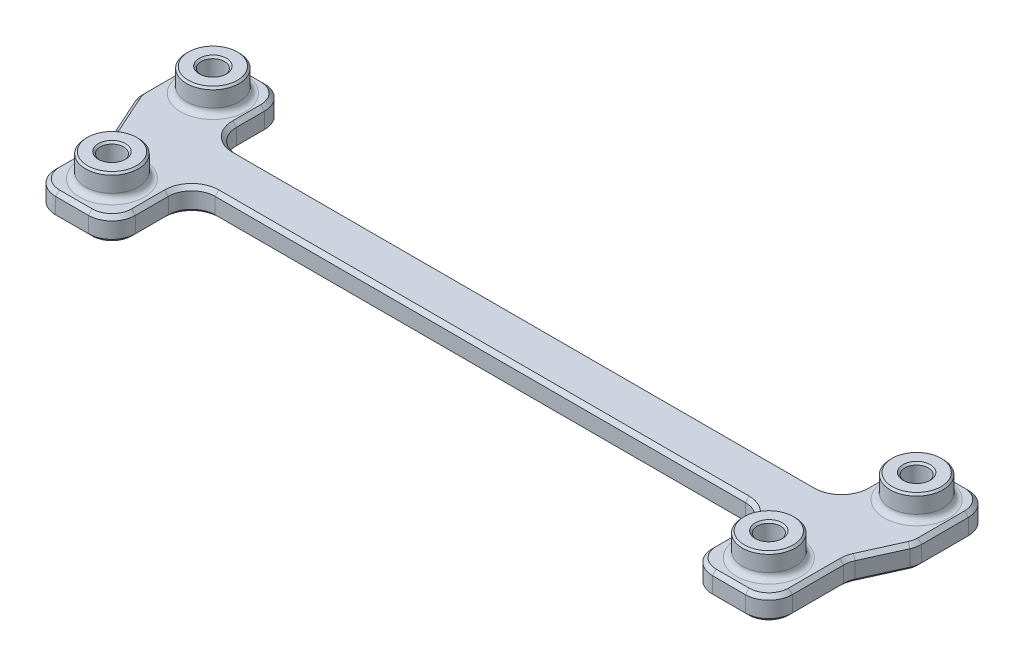
from build123d import *

# Parameters (mm, degrees)
BOSS_EXTRUDE2_DEPTH = 3.175
SKETCH3_R           = 3.571875
BOSS_EXTRUDE3_DEPTH = 3.175
CUT_EXTRUDE1_REACH  = 8.35
SKETCH4_R           = 1.5875
FILLET1_R           = 3.175
FILLET2_R           = 0.79375
CHAMFER1_SIZE       = 0.508
CHAMFER2_SIZE       = 0.254


with BuildPart() as part:
    # Sketch2 → Boss-Extrude2 (new body)
    with BuildSketch(Plane(origin=(0, 0, 0), x_dir=(1, 0, 0), z_dir=(0, 1, 0))):
        Polygon((-39.0525, -13.97), (-39.0525, -3.175), (39.0525, -3.175), (39.0525, -13.97), (49.8475, -13.97), (49.8475, -3.175), (52.71135, 3.175), (52.71135, 13.3477), (42.53865, 13.3477), (42.53865, 3.175), (-42.53865, 3.175), (-42.53865, 13.3477), (-52.71135, 13.3477), (-52.71135, 3.175), (-49.8475, -3.175), (-49.8475, -13.97), align=None)
    extrude(amount=BOSS_EXTRUDE2_DEPTH)

    # Sketch3 → Boss-Extrude3 (add)
    with BuildSketch(Plane(origin=(0, 3.175, 0), x_dir=(1, 0, 0), z_dir=(0, 1, 0))):
        with Locations((-47.625, 8.26135)):
            Circle(SKETCH3_R)
        with Locations((-44.45, -8.5725)):
            Circle(SKETCH3_R)
        with Locations((44.45, -8.5725)):
            Circle(SKETCH3_R)
        with Locations((47.625, 8.26135)):
            Circle(SKETCH3_R)
    extrude(amount=BOSS_EXTRUDE3_DEPTH)

    # Sketch4 → Cut-Extrude1 (cut, up to next)
    with BuildSketch(Plane.XZ, mode=Mode.PRIVATE) as cut_extrude1_sk1:
        with Locations((-44.45, 8.5725)):
            Circle(SKETCH4_R)
    cut_extrude1_tool1 = extrude(cut_extrude1_sk1.sketch, amount=-CUT_EXTRUDE1_REACH, mode=Mode.PRIVATE) & part.part
    add(cut_extrude1_tool1.solids().sort_by_distance((-44.45, 0, 8.5725))[0], mode=Mode.SUBTRACT)
    # Sketch4 → Cut-Extrude1 (cut, up to next)
    with BuildSketch(Plane.XZ, mode=Mode.PRIVATE) as cut_extrude1_sk2:
        with Locations((-47.625, -8.26135)):
            Circle(SKETCH4_R)
    cut_extrude1_tool2 = extrude(cut_extrude1_sk2.sketch, amount=-CUT_EXTRUDE1_REACH, mode=Mode.PRIVATE) & part.part
    add(cut_extrude1_tool2.solids().sort_by_distance((-47.625, 0, -8.26135))[0], mode=Mode.SUBTRACT)
    # Sketch4 → Cut-Extrude1 (cut, up to next)
    with BuildSketch(Plane.XZ, mode=Mode.PRIVATE) as cut_extrude1_sk3:
        with Locations((47.625, -8.26135)):
            Circle(SKETCH4_R)
    cut_extrude1_tool3 = extrude(cut_extrude1_sk3.sketch, amount=-CUT_EXTRUDE1_REACH, mode=Mode.PRIVATE) & part.part
    add(cut_extrude1_tool3.solids().sort_by_distance((47.625, 0, -8.26135))[0], mode=Mode.SUBTRACT)
    # Sketch4 → Cut-Extrude1 (cut, up to next)
    with BuildSketch(Plane.XZ, mode=Mode.PRIVATE) as cut_extrude1_sk4:
        with Locations((44.45, 8.5725)):
            Circle(SKETCH4_R)
    cut_extrude1_tool4 = extrude(cut_extrude1_sk4.sketch, amount=-CUT_EXTRUDE1_REACH, mode=Mode.PRIVATE) & part.part
    add(cut_extrude1_tool4.solids().sort_by_distance((44.45, 0, 8.5725))[0], mode=Mode.SUBTRACT)

    # Fillet1
    fillet1_edges = [part.edges().sort_by_distance(p)[0] for p in [
        (-42.53865, 1.5875, -13.3477),
        (-42.53865, 1.5875, -3.175),
        (42.53865, 1.5875, -3.175),
        (42.53865, 1.5875, -13.3477),
        (52.71135, 1.5875, -13.3477),
        (52.71135, 1.5875, -3.175),
        (49.8475, 1.5875, 3.175),
        (49.8475, 1.5875, 13.97),
        (39.0525, 1.5875, 13.97),
        (39.0525, 1.5875, 3.175),
        (-39.0525, 1.5875, 3.175),
        (-39.0525, 1.5875, 13.97),
        (-49.8475, 1.5875, 13.97),
        (-49.8475, 1.5875, 3.175),
        (-52.71135, 1.5875, -3.175),
        (-52.71135, 1.5875, -13.3477),
    ]]
    fillet(fillet1_edges, radius=FILLET1_R)

    # Fillet2
    fillet2_edges = [part.edges().sort_by_distance(p)[0] for p in [
        (-51.196875, 3.175, -8.26135),
        (-48.021875, 3.175, 8.5725),
        (44.053125, 3.175, -8.26135),
        (40.878125, 3.175, 8.5725),
    ]]
    fillet(fillet2_edges, radius=FILLET2_R)

    # Chamfer1
    chamfer1_edges = [part.edges().sort_by_distance(p)[0] for p in [
        (51.78141403, 0, -12.41776403),
        (43.46858597, 0, -12.41776403),
        (-43.46858597, 0, -12.41776403),
        (-42.53865, 3.175, -8.26135),
        (-52.71135, 3.175, -7.015272864),
        (-51.279425, 3.175, 0),
        (-49.8475, 3.175, 7.326422864),
        (-44.45, 3.175, 13.97),
        (-39.0525, 3.175, 8.5725),
        (0, 3.175, 3.175),
        (39.0525, 3.175, 8.5725),
        (44.45, 3.175, 13.97),
        (49.8475, 3.175, 7.326422864),
        (51.279425, 3.175, 0),
        (52.71135, 3.175, -7.015272864),
        (47.625, 3.175, -13.3477),
        (42.53865, 3.175, -8.26135),
        (0, 3.175, -3.175),
        (-51.78141403, 3.175, -12.41776403),
        (-52.640373335, 3.175, -3.190264917),
        (-48.91756403, 3.175, 13.04006403),
        (-39.98243597, 3.175, 13.04006403),
        (39.98243597, 3.175, 13.04006403),
        (48.91756403, 3.175, 13.04006403),
        (52.640373335, 3.175, -3.190264917),
        (51.78141403, 3.175, -12.41776403),
        (43.46858597, 3.175, -12.41776403),
        (-43.46858597, 3.175, -12.41776403),
        (-41.60871403, 0, -4.10493597),
        (-41.60871403, 3.175, -4.10493597),
        (41.60871403, 0, -4.10493597),
        (41.60871403, 3.175, -4.10493597),
        (49.918476665, 0, 3.190264917),
        (49.918476665, 3.175, 3.190264917),
        (38.12256403, 0, 4.10493597),
        (38.12256403, 3.175, 4.10493597),
        (-49.918476665, 0, 3.190264917),
        (-49.918476665, 3.175, 3.190264917),
        (-38.12256403, 0, 4.10493597),
        (-38.12256403, 3.175, 4.10493597),
        (-47.625, 0, -13.3477),
        (-47.625, 3.175, -13.3477),
        (-42.53865, 0, -8.26135),
        (0, 0, -3.175),
        (42.53865, 0, -8.26135),
        (47.625, 0, -13.3477),
        (52.71135, 0, -7.015272864),
        (51.279425, 0, 0),
        (49.8475, 0, 7.326422864),
        (44.45, 0, 13.97),
        (39.0525, 0, 8.5725),
        (0, 0, 3.175),
        (-39.0525, 0, 8.5725),
        (-44.45, 0, 13.97),
        (-49.8475, 0, 7.326422864),
        (-51.279425, 0, 0),
        (-52.71135, 0, -7.015272864),
        (-51.78141403, 0, -12.41776403),
        (-52.640373335, 0, -3.190264917),
        (-48.91756403, 0, 13.04006403),
        (-39.98243597, 0, 13.04006403),
        (39.98243597, 0, 13.04006403),
        (48.91756403, 0, 13.04006403),
        (52.640373335, 0, -3.190264917),
    ]]
    chamfer(chamfer1_edges, length=CHAMFER1_SIZE)

    # Chamfer2
    chamfer2_edges = [part.edges().sort_by_distance(p)[0] for p in [
        (-51.196875, 6.35, -8.26135),
        (-48.021875, 6.35, 8.5725),
        (44.053125, 6.35, -8.26135),
        (40.878125, 6.35, 8.5725),
        (42.8625, 6.35, 8.5725),
        (42.8625, 0, 8.5725),
        (46.0375, 6.35, -8.26135),
        (46.0375, 0, -8.26135),
        (-49.2125, 6.35, -8.26135),
        (-49.2125, 0, -8.26135),
        (-46.0375, 6.35, 8.5725),
        (-46.0375, 0, 8.5725),
    ]]
    chamfer(chamfer2_edges, length=CHAMFER2_SIZE)


solid = part.part
